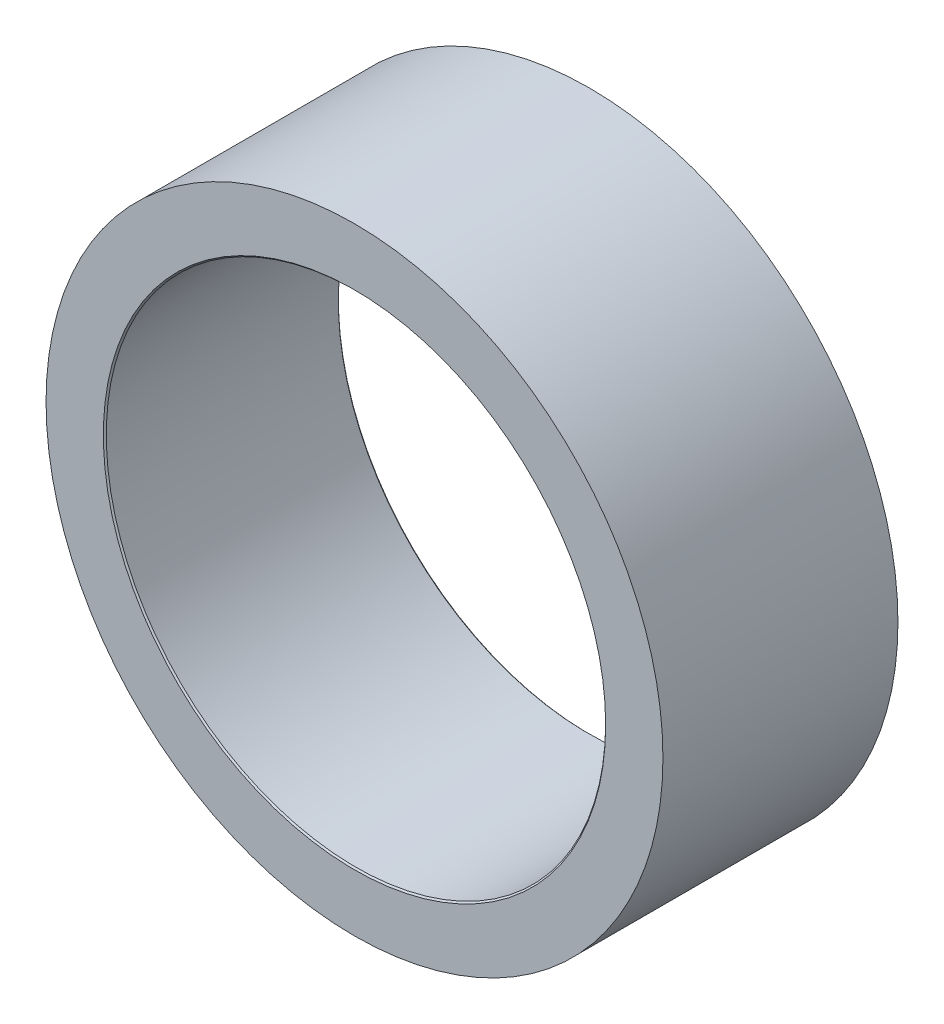
from build123d import *

# Parameters (mm, degrees)
SKETCH2_R           = 10.5
BOSS_EXTRUDE1_DEPTH = 8
SKETCH3_R           = 8.5
CUT_EXTRUDE1_DEPTH  = 9
CHAMFER1_SIZE       = 0.05
CHAMFER2_SIZE       = 0.05


with BuildPart() as part:
    # Sketch2 → Boss-Extrude1 (new body)
    with BuildSketch(Plane.XY):
        Circle(SKETCH2_R)
    extrude(amount=-BOSS_EXTRUDE1_DEPTH)

    # Sketch3 → Cut-Extrude1 (cut, through all)
    with BuildSketch(Plane.XY):
        Circle(SKETCH3_R)
    extrude(amount=-CUT_EXTRUDE1_DEPTH, mode=Mode.SUBTRACT)

    # Chamfer1
    chamfer1_edges = [part.edges().sort_by_distance(p)[0] for p in [
        (-8.5, 0, 0),
    ]]
    chamfer(chamfer1_edges, length=CHAMFER1_SIZE)

    # Chamfer2
    chamfer2_edges = [part.edges().sort_by_distance(p)[0] for p in [
        (-8.5, 0, -8),
    ]]
    chamfer(chamfer2_edges, length=CHAMFER2_SIZE)


solid = part.part
